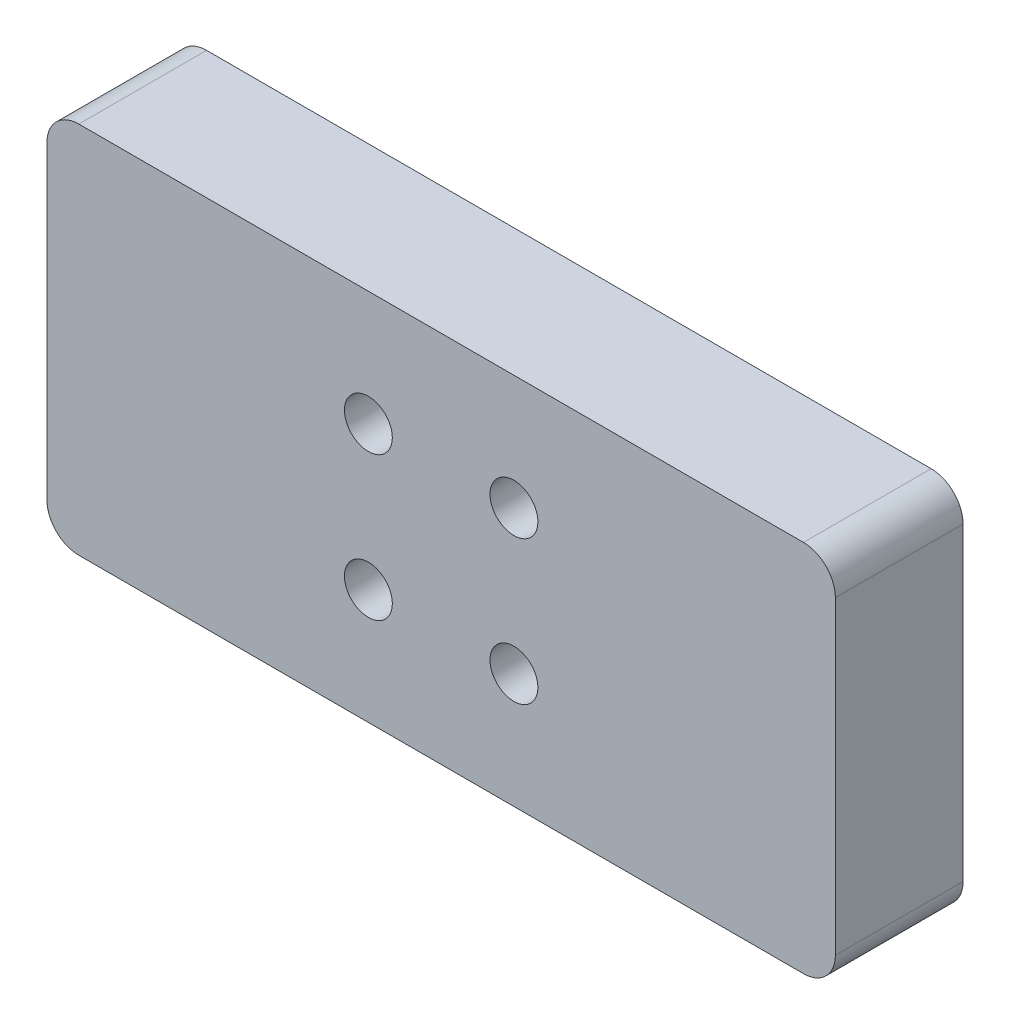
from build123d import *

# Parameters (mm, degrees)
SKETCH1_W           = 62.738
SKETCH1_H           = 29.718
BOSS_EXTRUDE1_DEPTH = 5.08
FILLET1_R           = 2.54
SKETCH2_R           = 1.905
CUT_EXTRUDE1_DEPTH  = 5
SKETCH3_R           = 1.905
CUT_EXTRUDE2_DEPTH  = 3


with BuildPart() as part:
    # Sketch1 → Boss-Extrude1 (new body, symmetric)
    with BuildSketch(Plane.XY):
        Rectangle(SKETCH1_W, SKETCH1_H)
    extrude(amount=BOSS_EXTRUDE1_DEPTH, both=True)

    # Fillet1
    fillet1_edges = [part.edges().sort_by_distance(p)[0] for p in [
        (31.369, -14.859, 0),
        (-31.369, -14.859, 0),
        (-31.369, 14.859, 0),
        (31.369, 14.859, 0),
    ]]
    fillet(fillet1_edges, radius=FILLET1_R)

    # Sketch2 → Cut-Extrude1 (cut, symmetric)
    with BuildSketch(Plane.XY.offset(5.08)):
        with Locations((-5.7912, 5.715)):
            Circle(SKETCH2_R)
        with Locations((5.7912, 5.715)):
            Circle(SKETCH2_R)
        with Locations((5.7912, -5.715)):
            Circle(SKETCH2_R)
        with Locations((-5.7912, -5.715)):
            Circle(SKETCH2_R)
    extrude(amount=CUT_EXTRUDE1_DEPTH, both=True, mode=Mode.SUBTRACT)

    # Sketch3 → Cut-Extrude2 (cut, symmetric)
    with BuildSketch(Plane(origin=(0, 0, -5.08), x_dir=(-1, 0, 0), z_dir=(0, 0, -1))):
        with Locations((-25.4, 7.9375)):
            Circle(SKETCH3_R)
        with Locations((-25.4, -7.9375)):
            Circle(SKETCH3_R)
        with Locations((25.4, -7.9375)):
            Circle(SKETCH3_R)
        with Locations((25.4, 7.9375)):
            Circle(SKETCH3_R)
    extrude(amount=CUT_EXTRUDE2_DEPTH, both=True, mode=Mode.SUBTRACT)


solid = part.part
